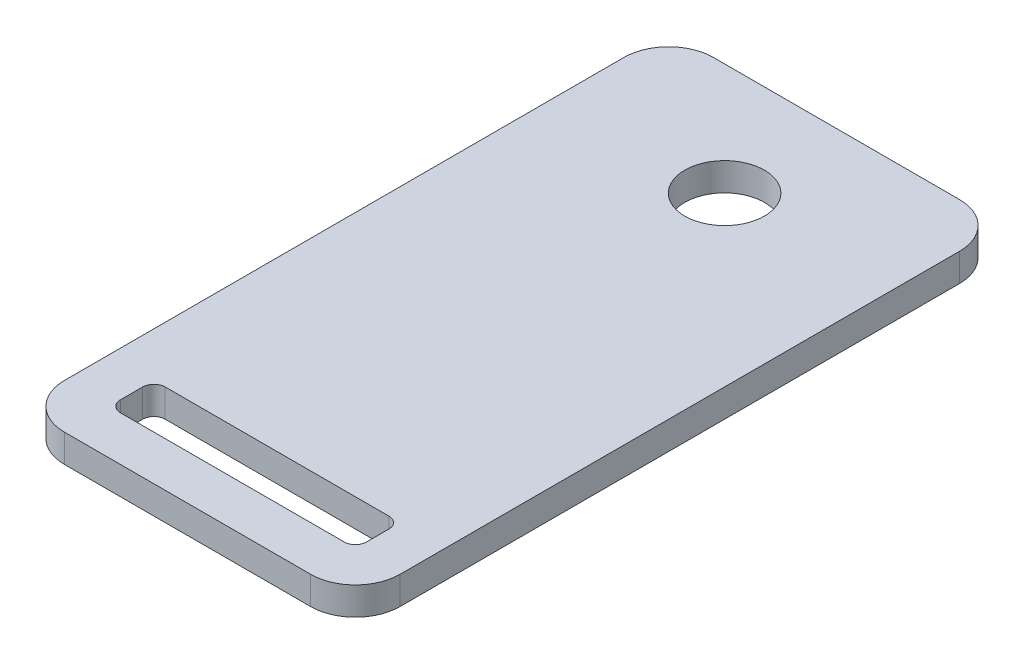
from build123d import *

# Parameters (mm, degrees)
SKETCH1_W           = 38.1
SKETCH1_H           = 73.66
SKETCH1_R           = 4.5212
SKETCH1_W_2         = 27.94
SKETCH1_H_2         = 5.08
BOSS_EXTRUDE1_DEPTH = 3.175
FILLET1_R           = 5.08
FILLET2_R           = 1.27


with BuildPart() as part:
    # Sketch1 → Boss-Extrude1 (new body)
    with BuildSketch(Plane(origin=(0, 0, 0), x_dir=(1, 0, 0), z_dir=(0, 1, 0))):
        with Locations((0, -24.13)):
            Rectangle(SKETCH1_W, SKETCH1_H)
        with Locations(Location((0, 0, 0), (0, 0, 270))):  # turned: the seam where the file's is
            Circle(SKETCH1_R, mode=Mode.SUBTRACT)
        with Locations((0, -53.34)):
            Rectangle(SKETCH1_W_2, SKETCH1_H_2, mode=Mode.SUBTRACT)
    extrude(amount=BOSS_EXTRUDE1_DEPTH)

    # Fillet1
    fillet1_edges = [part.edges().sort_by_distance(p)[0] for p in [
        (-19.05, 1.5875, -12.7),
        (19.05, 1.5875, -12.7),
        (19.05, 1.5875, 60.96),
        (-19.05, 1.5875, 60.96),
    ]]
    fillet(fillet1_edges, radius=FILLET1_R)

    # Fillet2
    fillet2_edges = [part.edges().sort_by_distance(p)[0] for p in [
        (-13.97, 1.5875, 50.8),
        (-13.97, 1.5875, 55.88),
        (13.97, 1.5875, 55.88),
        (13.97, 1.5875, 50.8),
    ]]
    fillet(fillet2_edges, radius=FILLET2_R)


solid = part.part
